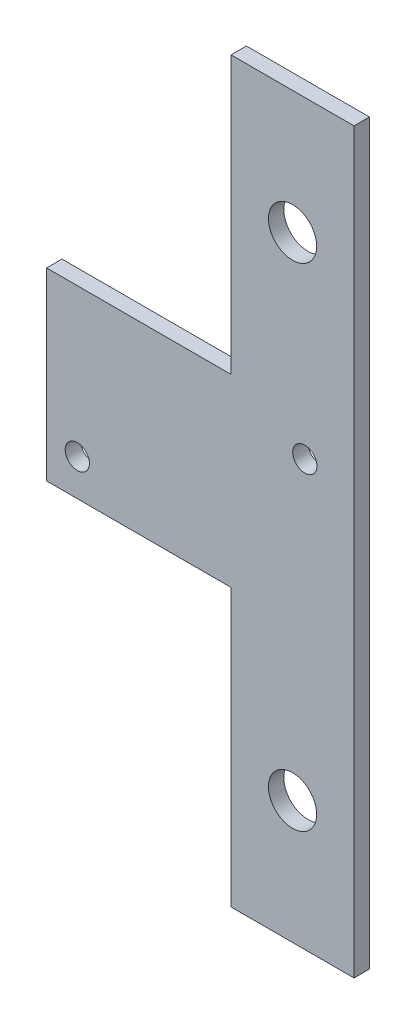
from build123d import *

# Parameters (mm, degrees)
SKETCH1_R           = 2.4892
SKETCH1_R_2         = 1.25
BOSS_EXTRUDE1_DEPTH = 1.5875


with BuildPart() as part:
    # Sketch1 → Boss-Extrude1 (new body)
    with BuildSketch(Plane.XY):
        Polygon((-12.384331799, 970.394541193), (-25.084331799, 970.394541193), (-25.084331799, 998.969541193), (-44.134331799, 998.969541193), (-44.134331799, 1018.019541193), (-25.084331799, 1018.019541193), (-25.084331799, 1046.594541193), (-12.384331799, 1046.594541193), align=None)
        with Locations((-18.734331799, 983.094541193)):
            Circle(SKETCH1_R, mode=Mode.SUBTRACT)
        with Locations((-18.734331799, 1033.894541193)):
            Circle(SKETCH1_R, mode=Mode.SUBTRACT)
        with Locations((-40.959331799, 1002.736275433)):
            Circle(SKETCH1_R_2, mode=Mode.SUBTRACT)
        with Locations((-17.467428821, 1014.252806953)):
            Circle(SKETCH1_R_2, mode=Mode.SUBTRACT)
    extrude(amount=BOSS_EXTRUDE1_DEPTH)


solid = part.part
